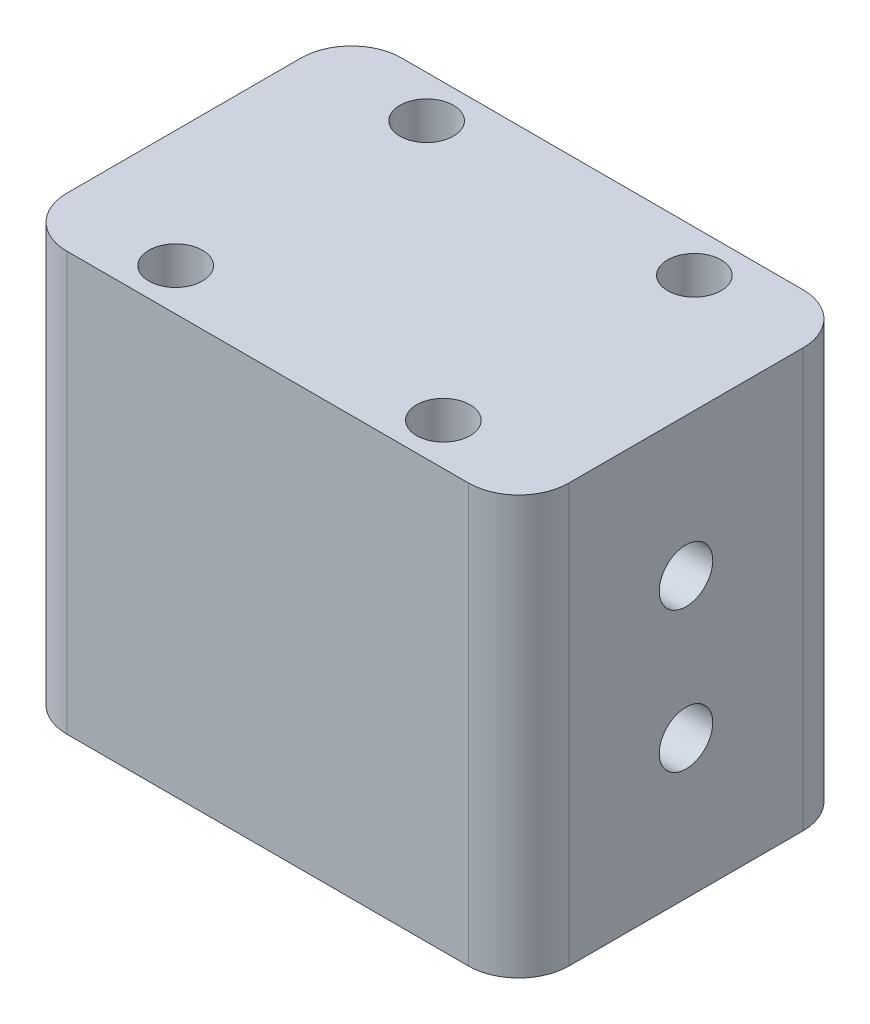
from build123d import *

# Parameters (mm, degrees)
SKETCH_1_W          = 30
SKETCH_1_H          = 20
SKETCH_1_R          = 1.6
EXTRUDE_1_DEPTH     = 25
FILLET_1_R          = 3
SKETCH_2_R          = 1.6
CUT_EXTRUDE_1_DEPTH = 31
SKETCH_3_R          = 1.6
EXTRUDE_2_DEPTH     = 30
SKETCH_4_R          = 1.6
CUT_EXTRUDE_2_DEPTH = 31


with BuildPart() as part:
    # 草图1 → 凸台-拉伸1 (new body)
    with BuildSketch(Plane(origin=(0, 0, 0), x_dir=(1, 0, 0), z_dir=(0, 1, 0))):
        Rectangle(SKETCH_1_W, SKETCH_1_H)
        with Locations((-8, 7.5)):
            Circle(SKETCH_1_R, mode=Mode.SUBTRACT)
        with Locations((-8, -7.5)):
            Circle(SKETCH_1_R, mode=Mode.SUBTRACT)
        with Locations((8, -7.5)):
            Circle(SKETCH_1_R, mode=Mode.SUBTRACT)
        with Locations((8, 7.5)):
            Circle(SKETCH_1_R, mode=Mode.SUBTRACT)
    extrude(amount=EXTRUDE_1_DEPTH)

    # 圆角1
    fillet_1_edges = [part.edges().sort_by_distance(p)[0] for p in [
        (15, 12.5, 10),
        (-15, 12.5, 10),
        (-15, 12.5, -10),
        (15, 12.5, -10),
    ]]
    fillet(fillet_1_edges, radius=FILLET_1_R)

    # 草图2 → 切除-拉伸1 (cut, through all)
    with BuildSketch(Plane(origin=(15, 0, 0), x_dir=(0, 0, -1), z_dir=(1, 0, 0))):
        with Locations((0, 16.7)):
            Circle(SKETCH_2_R)
        with Locations((0, 8.3)):
            Circle(SKETCH_2_R)
    extrude(amount=-CUT_EXTRUDE_1_DEPTH, mode=Mode.SUBTRACT)

    # 草图3 → 凸台-拉伸2 (add)
    with BuildSketch(Plane(origin=(15, 0, 0), x_dir=(0, 0, -1), z_dir=(1, 0, 0))):
        with Locations((0, 16.7)):
            Circle(SKETCH_3_R)
    extrude(amount=-EXTRUDE_2_DEPTH)

    # 草图4 → 切除-拉伸2 (cut, through all)
    with BuildSketch(Plane(origin=(15, 0, 0), x_dir=(0, 0, -1), z_dir=(1, 0, 0))):
        with Locations((0, 16.7)):
            Circle(SKETCH_4_R)
    extrude(amount=-CUT_EXTRUDE_2_DEPTH, mode=Mode.SUBTRACT)


solid = part.part
